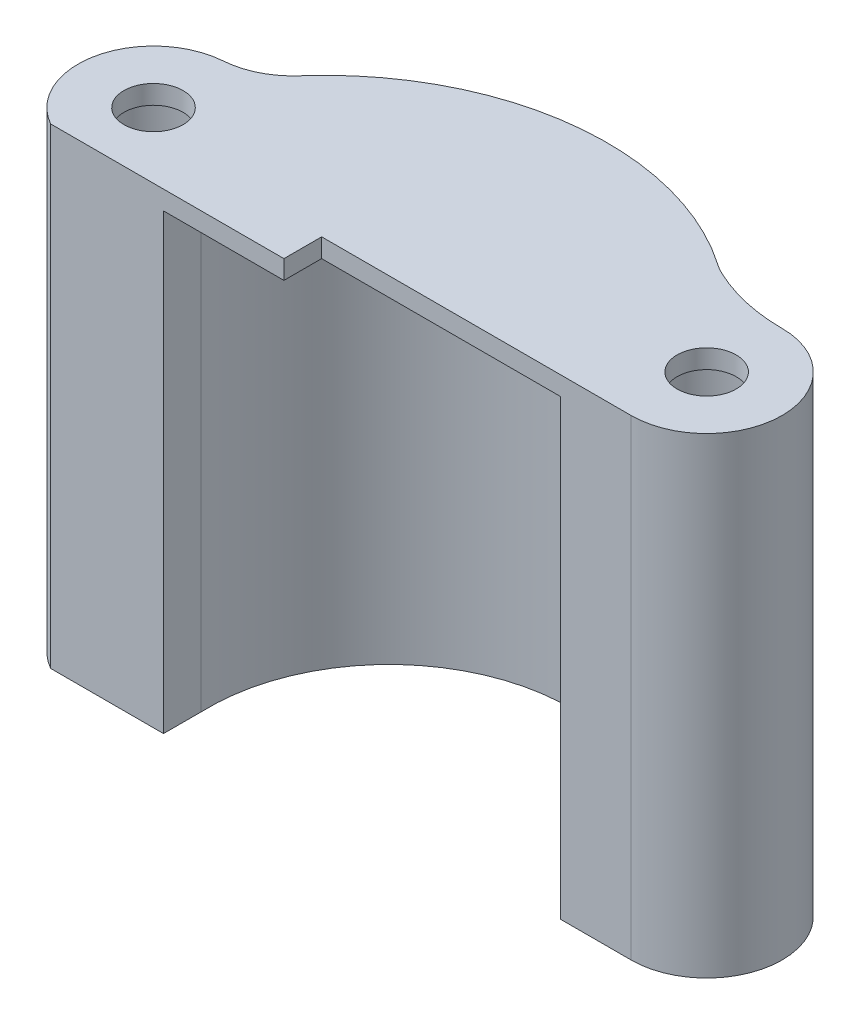
from build123d import *

# Parameters (mm, degrees)
SKETCH2_R           = 4.7625
BOSS_EXTRUDE1_DEPTH = 38.1
SKETCH3_R           = 2.4892
BOSS_EXTRUDE2_DEPTH = 1.5875
SKETCH4_W           = 20.112893425
SKETCH4_H           = 3.175
SKETCH4_W_2         = 10.134015187
BOSS_EXTRUDE3_DEPTH = 1.5875
FILLET2_R           = 6.35


with BuildPart() as part:
    # Sketch2 → Boss-Extrude1 (new body)
    with BuildSketch(Plane(origin=(0, 0, 0), x_dir=(1, 0, 0), z_dir=(0, 1, 0))):
        with BuildLine():
            Line((-13.637822674, -18.9154966), (-13.637822674, -15.7404966))
            ThreePointArc((-13.637822674, -15.7404966), (0, 0), (16.609085938, -12.5654966))
            Line((16.609085938, -12.5654966), (16.609085938, -15.7404966))
            Line((16.609085938, -15.7404966), (22.545691393, -15.7404966))
            ThreePointArc((22.545691393, -15.7404966), (28.895691393, -9.3904966), (22.545691393, -3.0404966))
            ThreePointArc((22.545691393, -3.0404966), (18.914562129, -2.601594541), (15.492581173, -1.310168551))
            ThreePointArc((15.492581173, -1.310168551), (-2.207478742, 2.815047226), (-17.640279185, -6.783817119))
            ThreePointArc((-17.640279185, -6.783817119), (-18.810770101, -6.984553123), (-19.996688426, -7.047335697))
            ThreePointArc((-19.996688426, -7.047335697), (-26.135207048, -11.772192893), (-23.138726022, -18.9154966))
            Line((-23.138726022, -18.9154966), (-13.637822674, -18.9154966))
        make_face()
        with Locations((-19.996688426, -13.397335697)):
            Circle(SKETCH2_R, mode=Mode.SUBTRACT)
        with Locations((22.545691393, -9.3904966)):
            Circle(SKETCH2_R, mode=Mode.SUBTRACT)
    extrude(amount=BOSS_EXTRUDE1_DEPTH)

    # Sketch3 → Boss-Extrude2 (add)
    with BuildSketch(Plane(origin=(0, 38.1, 0), x_dir=(-1, 0, 0), z_dir=(0, 1, 0))):
        with BuildLine():
            Line((13.637822674, 15.7404966), (3.503807487, 15.7404966))
            Line((3.503807487, 15.7404966), (3.503807487, 12.5654966))
            Line((3.503807487, 12.5654966), (-16.609085938, 12.5654966))
            Line((-16.609085938, 12.5654966), (-16.609085938, 15.7404966))
            Line((-16.609085938, 15.7404966), (-22.545691393, 15.7404966))
            ThreePointArc((-22.545691393, 15.7404966), (-28.895691393, 9.3904966), (-22.545691393, 3.0404966))
            ThreePointArc((-22.545691393, 3.0404966), (-18.914562129, 2.601594541), (-15.492581173, 1.310168551))
            ThreePointArc((-15.492581173, 1.310168551), (2.207478742, -2.815047226), (17.640279185, 6.783817119))
            ThreePointArc((17.640279185, 6.783817119), (18.810770101, 6.984553123), (19.996688426, 7.047335697))
            ThreePointArc((19.996688426, 7.047335697), (26.135207048, 11.772192893), (23.138726022, 18.9154966))
            Line((23.138726022, 18.9154966), (13.637822674, 18.9154966))
            Line((13.637822674, 18.9154966), (13.637822674, 15.7404966))
        make_face()
        with Locations((-22.545691393, 9.3904966)):
            Circle(SKETCH3_R, mode=Mode.SUBTRACT)
        with Locations((19.996688426, 13.397335697)):
            Circle(SKETCH3_R, mode=Mode.SUBTRACT)
    extrude(amount=BOSS_EXTRUDE2_DEPTH)

    # Sketch4 → Boss-Extrude3 (add)
    with BuildSketch(Plane(origin=(0, 39.6875, 0), x_dir=(-1, 0, 0), z_dir=(0, 1, 0))):
        with Locations((-6.552639226, 14.1529966)):
            Rectangle(SKETCH4_W, SKETCH4_H)
        with Locations((8.570815081, 17.3279966)):
            Rectangle(SKETCH4_W_2, SKETCH4_H)
    extrude(amount=-BOSS_EXTRUDE3_DEPTH)

    # Fillet2
    fillet2_edges = [part.edges().sort_by_distance(p)[0] for p in [
        (15.492581173, 19.84375, 1.310168551),
        (-17.640279185, 19.84375, 6.783817119),
    ]]
    fillet(fillet2_edges, radius=FILLET2_R)


solid = part.part
